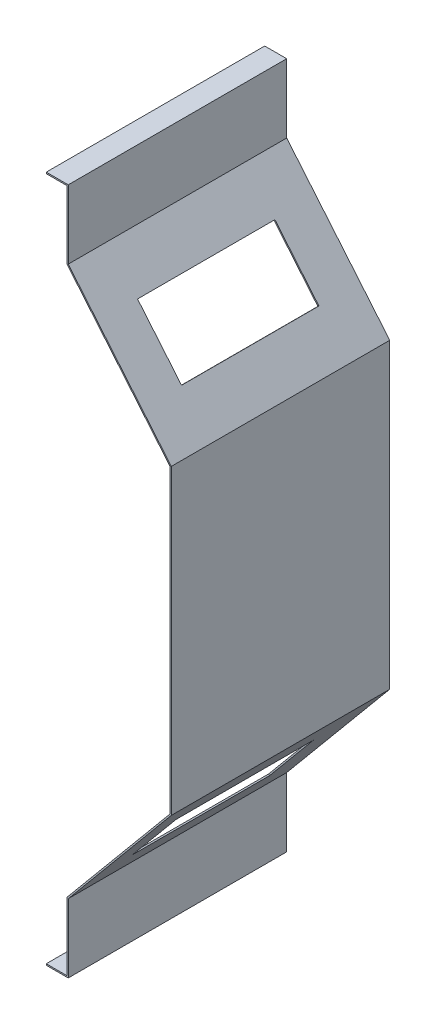
from build123d import *

# Parameters (mm, degrees)
BOSS_EXTRUDE1_DEPTH = 159
SKETCH2_W           = 100
SKETCH2_H           = 50
CUT_EXTRUDE1_DEPTH  = 160
SKETCH5_W           = 100
SKETCH5_H           = 50
CUT_EXTRUDE2_DEPTH  = 160


with BuildPart() as part:
    # Sketch1 → Boss-Extrude1 (new body)
    with BuildSketch(Plane.XY):
        Polygon((0, 110), (0, -110), (-75, -200), (-75, -249), (-75, -250), (-91, -250), (-91, -249), (-76, -249), (-76, -199.637950065), (-1, -109.637950065), (-1, 109.637950065), (-76, 199.637950065), (-76, 249), (-91, 249), (-91, 250), (-75, 250), (-75, 249), (-75, 200), align=None)
    extrude(amount=BOSS_EXTRUDE1_DEPTH)

    # Sketch2 → Cut-Extrude1 (cut)
    with BuildSketch(Plane(origin=(54.098360656, -45.081967213, 0), x_dir=(0, 0, -1), z_dir=(0.76822128, -0.6401844, 0))):
        with Locations((-84, -143.004340756)):
            Rectangle(SKETCH2_W, SKETCH2_H)
    extrude(amount=-CUT_EXTRUDE1_DEPTH, mode=Mode.SUBTRACT)

    # Sketch5 → Cut-Extrude2 (cut)
    with BuildSketch(Plane(origin=(54.098360656, 45.081967213, 0), x_dir=(0, 0, -1), z_dir=(0.76822128, 0.6401844, 0))):
        with Locations((-80, 143.158085894)):
            Rectangle(SKETCH5_W, SKETCH5_H)
    extrude(amount=-CUT_EXTRUDE2_DEPTH, mode=Mode.SUBTRACT)


solid = part.part
